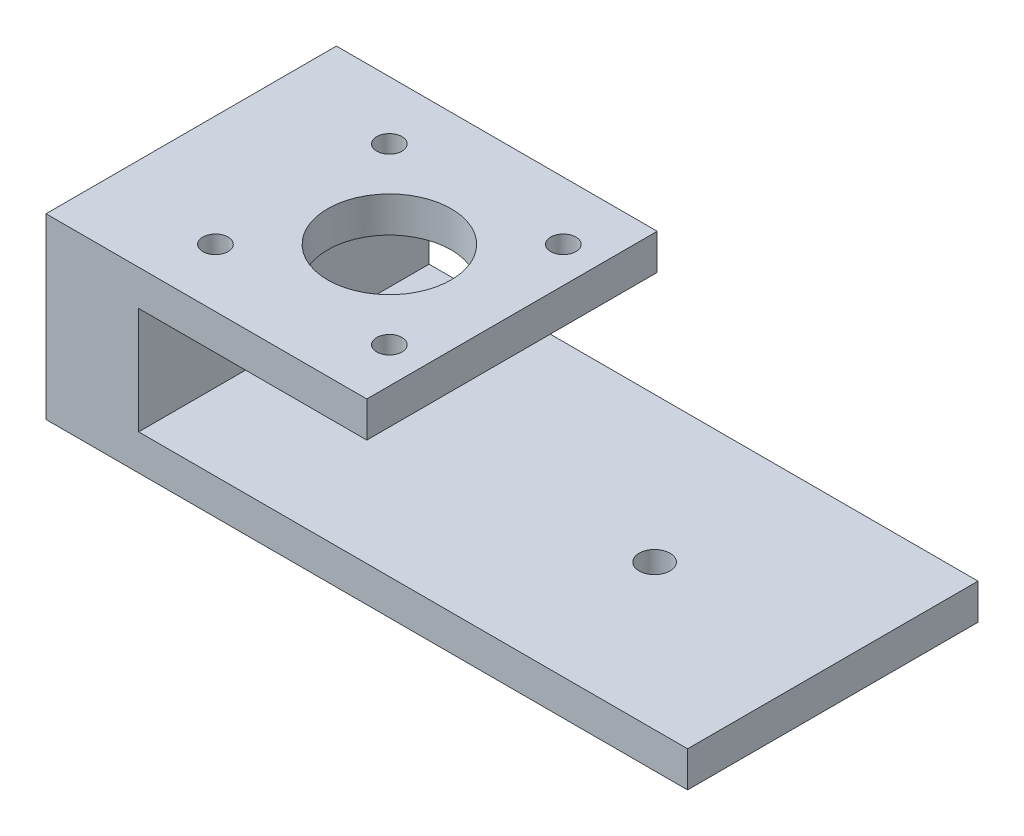
from build123d import *

# Parameters (mm, degrees)
SKETCH1_W                = 114.3
SKETCH1_H                = 51.7398
BOSS_EXTRUDE1_DEPTH      = 6.35
M5_CLEARANCE_HOLE1_D     = 5.5
M5_CLEARANCE_HOLE1_DEPTH = 6.35
SKETCH6_W                = 16.51
SKETCH6_H                = 51.7398
BOSS_EXTRUDE2_DEPTH      = 19.05
SKETCH7_W                = 57.15
SKETCH7_H                = 51.7398
BOSS_EXTRUDE3_DEPTH      = 6.35
SKETCH10_R               = 10.9982
CUT_EXTRUDE1_DEPTH       = 6.35
M4_CLEARANCE_HOLE1_D     = 4.5
M4_CLEARANCE_HOLE1_DEPTH = 6.35


with BuildPart() as part:
    # Sketch1 → Boss-Extrude1 (new body)
    with BuildSketch(Plane(origin=(0, 0, 0), x_dir=(1, 0, 0), z_dir=(0, 1, 0))):
        Rectangle(SKETCH1_W, SKETCH1_H)
    extrude(amount=BOSS_EXTRUDE1_DEPTH)

    # M5 Clearance Hole1
    with Locations(Plane(origin=(0, 6.35, 0), x_dir=(1, 0, 0), z_dir=(0, 1, 0))):
        with Locations((25.4, 0), (-21.844, 0)):
            Hole(M5_CLEARANCE_HOLE1_D / 2, depth=M5_CLEARANCE_HOLE1_DEPTH)

    # Sketch6 → Boss-Extrude2 (add)
    with BuildSketch(Plane(origin=(0, 6.35, 0), x_dir=(1, 0, 0), z_dir=(0, 1, 0))):
        with Locations((-48.895, 0)):
            Rectangle(SKETCH6_W, SKETCH6_H)
    extrude(amount=BOSS_EXTRUDE2_DEPTH)

    # Sketch7 → Boss-Extrude3 (add)
    with BuildSketch(Plane(origin=(0, 25.4, 0), x_dir=(1, 0, 0), z_dir=(0, 1, 0))):
        with Locations((-28.575, 0)):
            Rectangle(SKETCH7_W, SKETCH7_H)
    extrude(amount=BOSS_EXTRUDE3_DEPTH)

    # Sketch10 → Cut-Extrude1 (cut)
    with BuildSketch(Plane(origin=(0, 31.75, 0), x_dir=(1, 0, 0), z_dir=(0, 1, 0))):
        with Locations((-21.844, 0)):
            Circle(SKETCH10_R)
    extrude(amount=-CUT_EXTRUDE1_DEPTH, mode=Mode.SUBTRACT)

    # M4 Clearance Hole1
    with Locations(Plane(origin=(0, 31.75, 0), x_dir=(1, 0, 0), z_dir=(0, 1, 0))):
        with Locations((-6.35, 15.494), (-37.338, 15.494), (-37.338, -15.494), (-6.35, -15.494)):
            Hole(M4_CLEARANCE_HOLE1_D / 2, depth=M4_CLEARANCE_HOLE1_DEPTH)


solid = part.part
